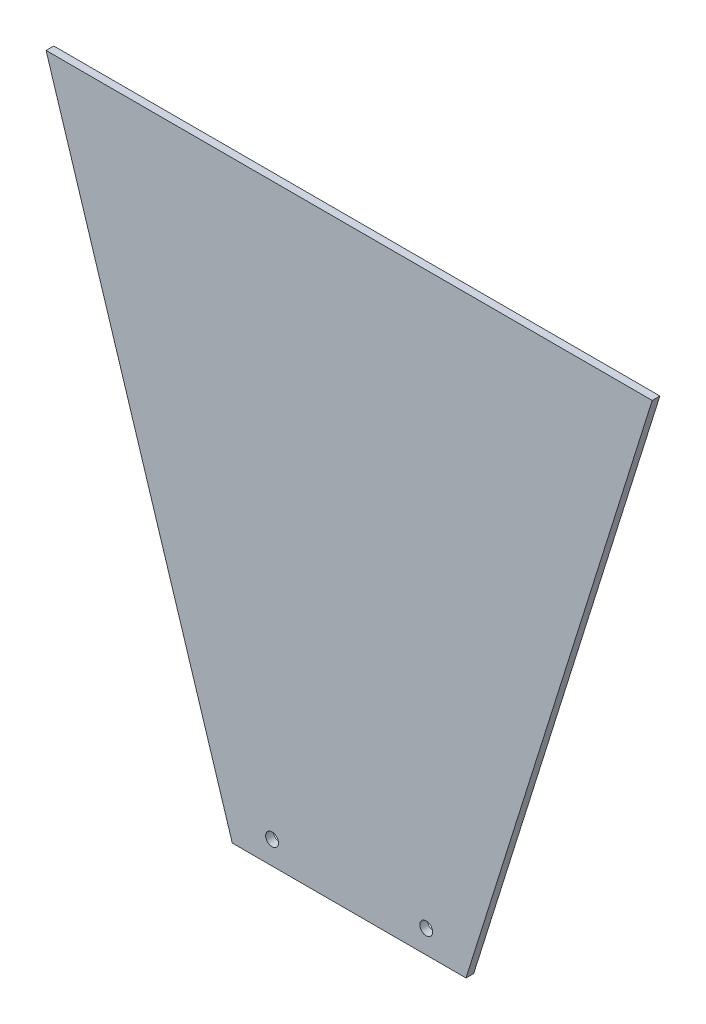
from build123d import *

# Parameters (mm, degrees)
CROQUIS1_R              = 2.5
SALIENTE_EXTRUIR1_DEPTH = 3


with BuildPart() as part:
    # Croquis1 → Saliente-Extruir1 (new body)
    with BuildSketch(Plane.XY):
        Polygon((-45.5, 0), (-118, 231), (118, 231), (45.5, 0), align=None)
        with Locations((-30, 9)):
            Circle(CROQUIS1_R, mode=Mode.SUBTRACT)
        with Locations((30, 9)):
            Circle(CROQUIS1_R, mode=Mode.SUBTRACT)
    extrude(amount=SALIENTE_EXTRUIR1_DEPTH)


solid = part.part
